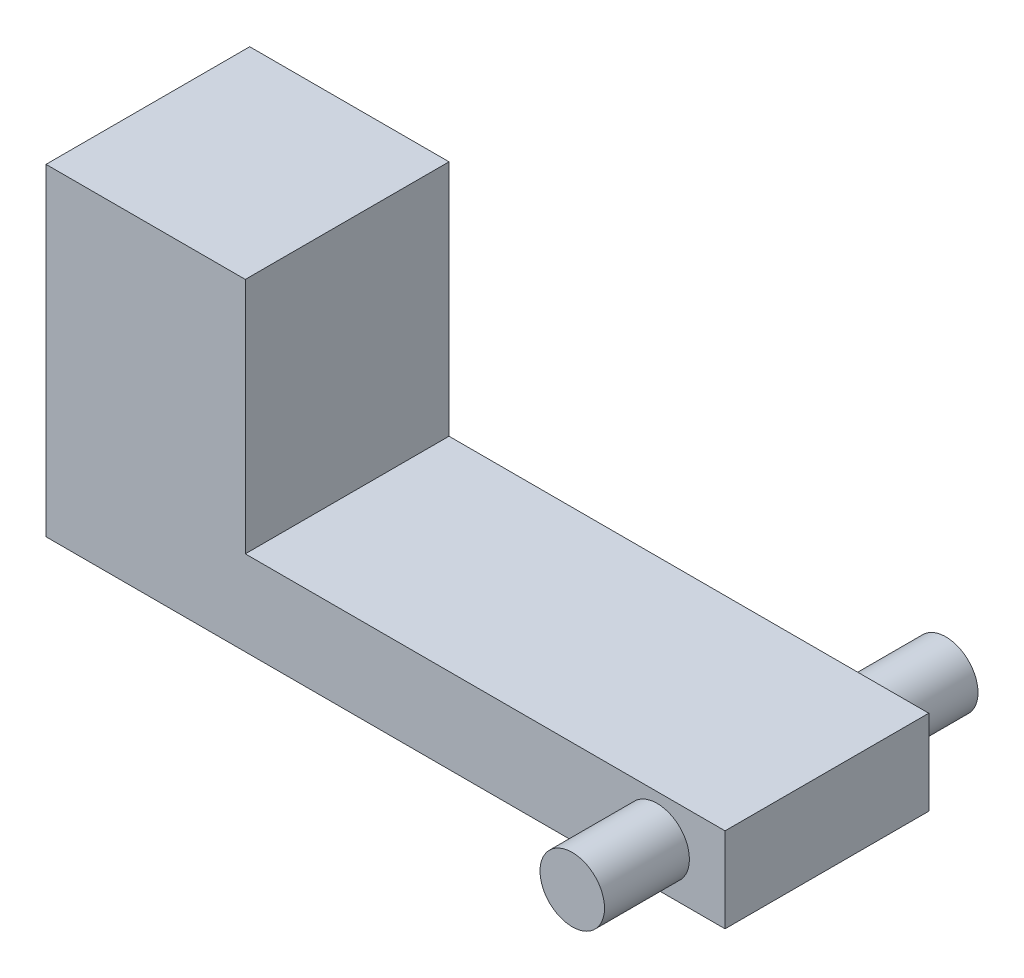
from build123d import *

# Parameters (mm, degrees)
SKETCH1_W                = 20
SKETCH1_H                = 6
BOSS_EXTRUDE1_DEPTH      = 2.5
SKETCH2_R                = 0.95
BOSS_EXTRUDE2_DEPTH      = 2.5
BOSS_EXTRUDE2_DEPTH_BACK = 8.5
SKETCH4_W                = 5.869913051
SKETCH4_H                = 6
BOSS_EXTRUDE3_DEPTH      = 7


with BuildPart() as part:
    # Sketch1 → Boss-Extrude1 (new body)
    with BuildSketch(Plane(origin=(0, 0, 0), x_dir=(1, 0, 0), z_dir=(0, 1, 0))):
        Rectangle(SKETCH1_W, SKETCH1_H)
    extrude(amount=BOSS_EXTRUDE1_DEPTH)

    # Sketch2 → Boss-Extrude2 (add, two sides)
    with BuildSketch(Plane.XY.offset(3)) as boss_extrude2_sk:
        with Locations((8, 1.25)):
            Circle(SKETCH2_R)
    extrude(amount=BOSS_EXTRUDE2_DEPTH)
    extrude(boss_extrude2_sk.sketch, amount=-BOSS_EXTRUDE2_DEPTH_BACK)

    # Sketch4 → Boss-Extrude3 (add)
    with BuildSketch(Plane(origin=(0, 2.5, 0), x_dir=(1, 0, 0), z_dir=(0, 1, 0))):
        with Locations((-7.065043474, 0)):
            Rectangle(SKETCH4_W, SKETCH4_H)
    extrude(amount=BOSS_EXTRUDE3_DEPTH)


solid = part.part
